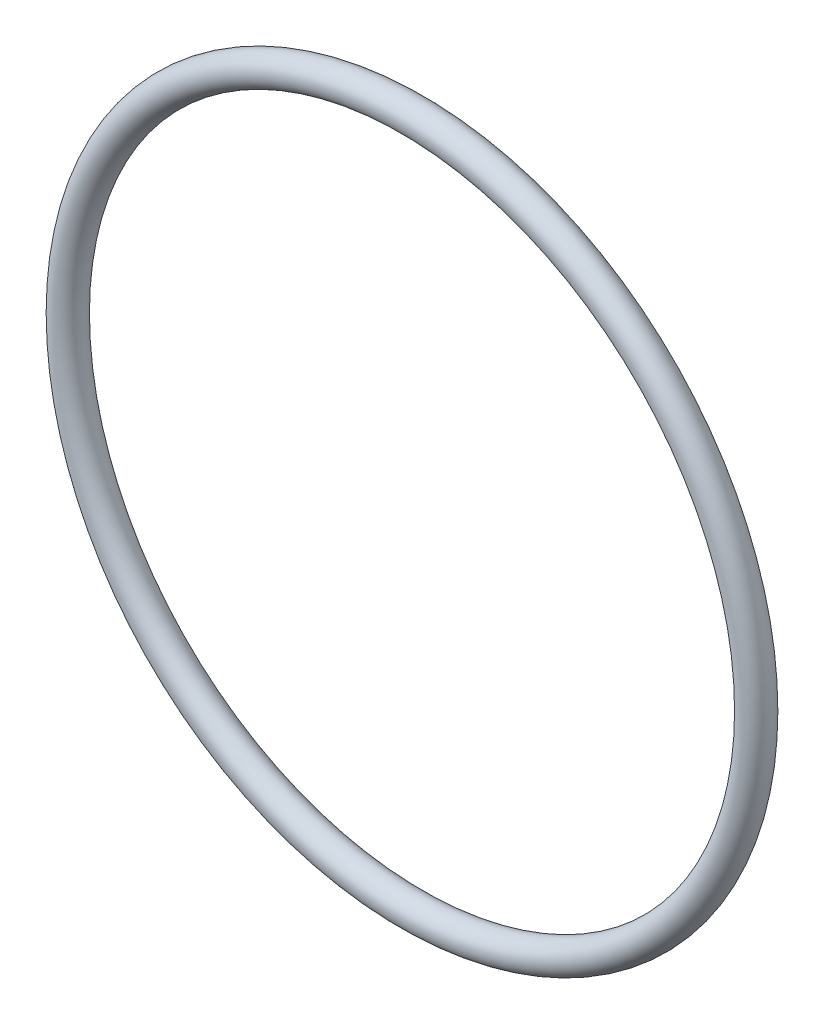
from build123d import *

# Parameters (mm, degrees)
SKETCH1_R = 1.7653


with BuildPart() as part:
    # Sketch1 → Revolve1 (revolve)
    with BuildSketch(Plane(origin=(0, 0, 0), x_dir=(0, -1, 0), z_dir=(1, 0, 0))):
        with Locations((39.6621, 0)):
            Circle(SKETCH1_R)
    revolve(axis=Axis((0, 0, 1.7653), (0, 0, -1)))


solid = part.part
